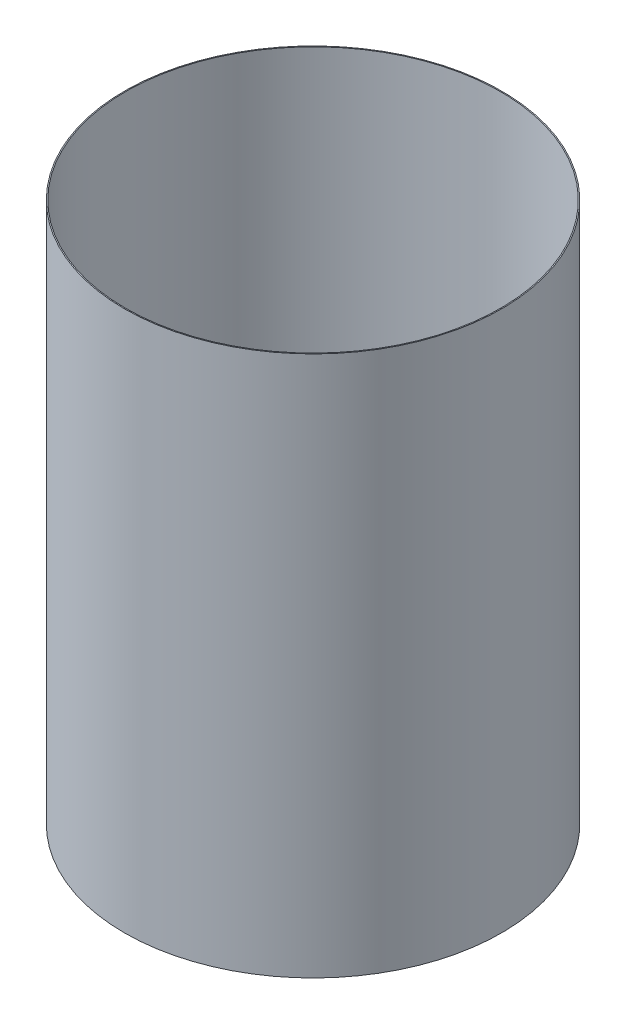
from build123d import *

# Parameters (mm, degrees)
SKETCH1_W = 0.254
SKETCH1_H = 133.35


with BuildPart() as part:
    # Sketch1 → Revolve-Thin1 (revolve)
    with BuildSketch(Plane.XY):
        with Locations((-46.41215, -86.580914232)):
            Rectangle(SKETCH1_W, SKETCH1_H)
    revolve(axis=Axis((0, 55, 0), (0, -1, 0)))


solid = part.part
